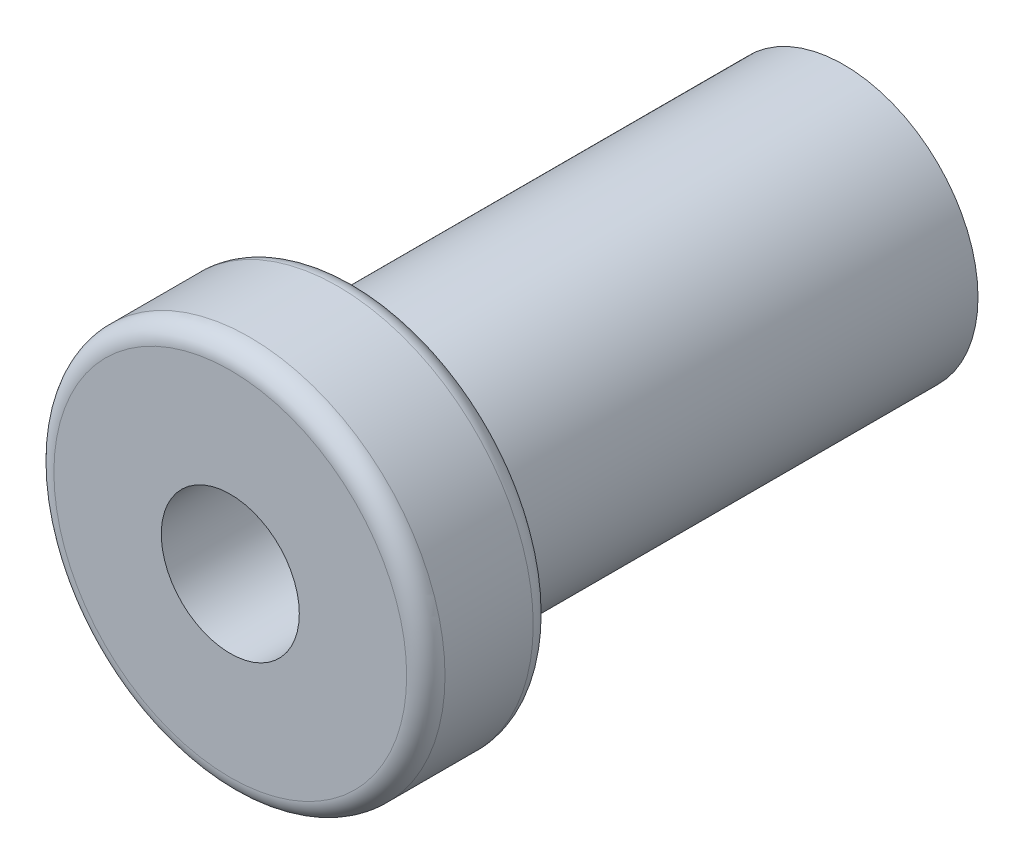
from build123d import *

# Parameters (mm, degrees)
FILLET1_R          = 0.5
SKETCH2_R          = 1.8
CUT_EXTRUDE1_DEPTH = 14


with BuildPart() as part:
    # Sketch1 → Revolve3 (revolve)
    with BuildSketch(Plane(origin=(0, 0, 0), x_dir=(0, 0, -1), z_dir=(1, 0, 0))):
        Polygon((0, 5.1), (-3.3, 5.1), (-3.3, 0), (12.7, 0), (12.7, 3.5), (0, 3.5), align=None)
    revolve(axis=Axis((0, 0, 0), (0, 0, -1)))

    # Fillet1
    fillet1_edges = [part.edges().sort_by_distance(p)[0] for p in [
        (0, -5.1, 3.3),
        (0, -5.1, 0),
    ]]
    fillet(fillet1_edges, radius=FILLET1_R)

    # Sketch2 → Cut-Extrude1 (cut)
    with BuildSketch(Plane.XY.offset(3.3)):
        Circle(SKETCH2_R)
    extrude(amount=-CUT_EXTRUDE1_DEPTH, mode=Mode.SUBTRACT)


solid = part.part
